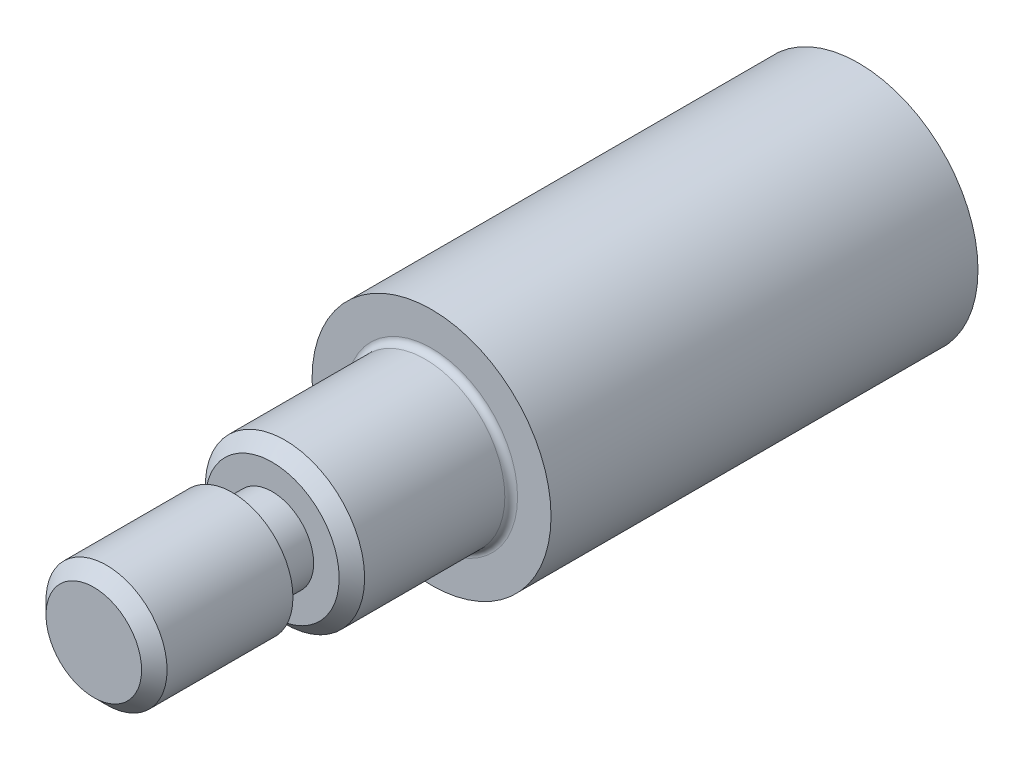
from build123d import *

# Parameters (mm, degrees)
SKETCH1_R                  = 4.7625
BOSS_EXTRUDE1_DEPTH        = 17.018
SKETCH2_R                  = 3.175
BOSS_EXTRUDE2_DEPTH        = 6.35
SKETCH4_R                  = 2.413
BOSS_EXTRUDE3_DEPTH        = 7.112
SKETCH5_R                  = 3.19405
CUT_EXTRUDE2_DEPTH         = 5.842
CHAMFER1_SIZE              = 0.254
FILLET1_R                  = 0.254
CHAMFER2_SIZE              = 0.508
F_10_24_TAPPED_HOLE1_D     = 3.7973
F_10_24_TAPPED_HOLE1_DEPTH = 8.89
F_10_24_TAPPED_HOLE1_TIP   = 1.140824014
CHAMFER3_SIZE              = 0.508
SKETCH10_W                 = 0.762
SKETCH10_H                 = 1.5875
FILLET2_R                  = 0.254


with BuildPart() as part:
    # Sketch1 → Boss-Extrude1 (new body)
    with BuildSketch(Plane.XY):
        Circle(SKETCH1_R)
    extrude(amount=BOSS_EXTRUDE1_DEPTH)

    # Sketch2 → Boss-Extrude2 (add)
    with BuildSketch(Plane.XY.offset(17.018)):
        Circle(SKETCH2_R)
    extrude(amount=BOSS_EXTRUDE2_DEPTH)

    # Sketch4 → Boss-Extrude3 (add)
    with BuildSketch(Plane.XY.offset(23.368)):
        Circle(SKETCH4_R)
    extrude(amount=BOSS_EXTRUDE3_DEPTH)

    # Sketch5 → Cut-Extrude2 (cut)
    with BuildSketch(Plane(origin=(0, 0, 0), x_dir=(-1, 0, 0), z_dir=(0, 0, -1))):
        Circle(SKETCH5_R)
    extrude(amount=-CUT_EXTRUDE2_DEPTH, mode=Mode.SUBTRACT)

    # Chamfer1
    chamfer1_edges = [part.edges().sort_by_distance(p)[0] for p in [
        (3.19405, 0, 0),
    ]]
    chamfer(chamfer1_edges, length=CHAMFER1_SIZE)

    # Fillet1
    fillet1_edges = [part.edges().sort_by_distance(p)[0] for p in [
        (3.19405, 0, 5.842),
    ]]
    fillet(fillet1_edges, radius=FILLET1_R)

    # Chamfer2
    chamfer2_edges = [part.edges().sort_by_distance(p)[0] for p in [
        (-3.175, 0, 23.368),
    ]]
    chamfer(chamfer2_edges, length=CHAMFER2_SIZE)

    # #10-24 Tapped Hole1
    with Locations(Plane(origin=(0, 0, 5.842), x_dir=(-1, 0, 0), z_dir=(0, 0, -1))):
        with Locations((0, 0)):
            Hole(F_10_24_TAPPED_HOLE1_D / 2, depth=F_10_24_TAPPED_HOLE1_DEPTH)
            with Locations((0, 0, -(F_10_24_TAPPED_HOLE1_DEPTH + F_10_24_TAPPED_HOLE1_TIP / 2))):  # 118° drill point
                Cone(0, F_10_24_TAPPED_HOLE1_D / 2, F_10_24_TAPPED_HOLE1_TIP, mode=Mode.SUBTRACT)

    # Chamfer3
    chamfer3_edges = [part.edges().sort_by_distance(p)[0] for p in [
        (-2.413, 0, 30.48),
    ]]
    chamfer(chamfer3_edges, length=CHAMFER3_SIZE)

    # Sketch10 → Cut-Revolve1 (revolve, cut)
    with BuildSketch(Plane(origin=(0, 0, 0), x_dir=(1, 0, 0), z_dir=(0, 1, 0))):
        with Locations((-2.032, -24.16175)):
            Rectangle(SKETCH10_W, SKETCH10_H)
    revolve(axis=Axis((0, 0, 29.927585912), (0, 0, -1)), mode=Mode.SUBTRACT)

    # Fillet2
    fillet2_edges = [part.edges().sort_by_distance(p)[0] for p in [
        (-3.175, 0, 17.018),
    ]]
    fillet(fillet2_edges, radius=FILLET2_R)


solid = part.part
